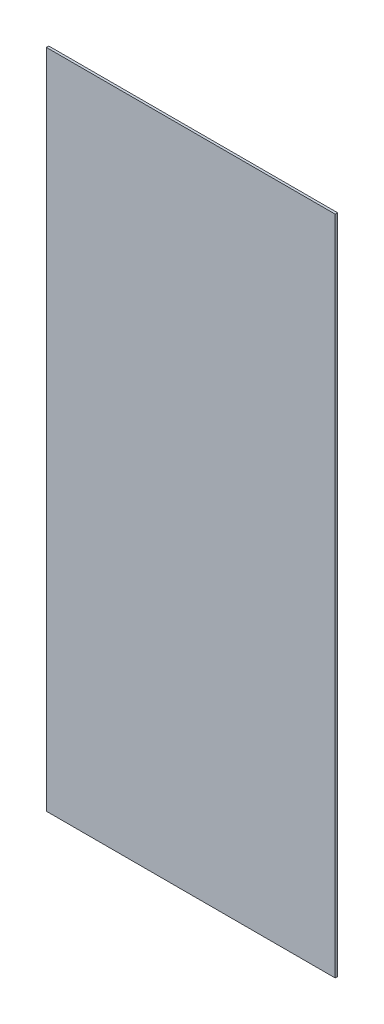
from build123d import *

# Parameters (mm, degrees)
SKETCH_1_W      = 358
SKETCH_1_H      = 820
EXTRUDE_1_DEPTH = 3


with BuildPart() as part:
    # 스케치1 → 보스-돌출1 (new body)
    with BuildSketch(Plane.XY):
        with Locations((179, 410)):
            Rectangle(SKETCH_1_W, SKETCH_1_H)
    extrude(amount=EXTRUDE_1_DEPTH)


solid = part.part
